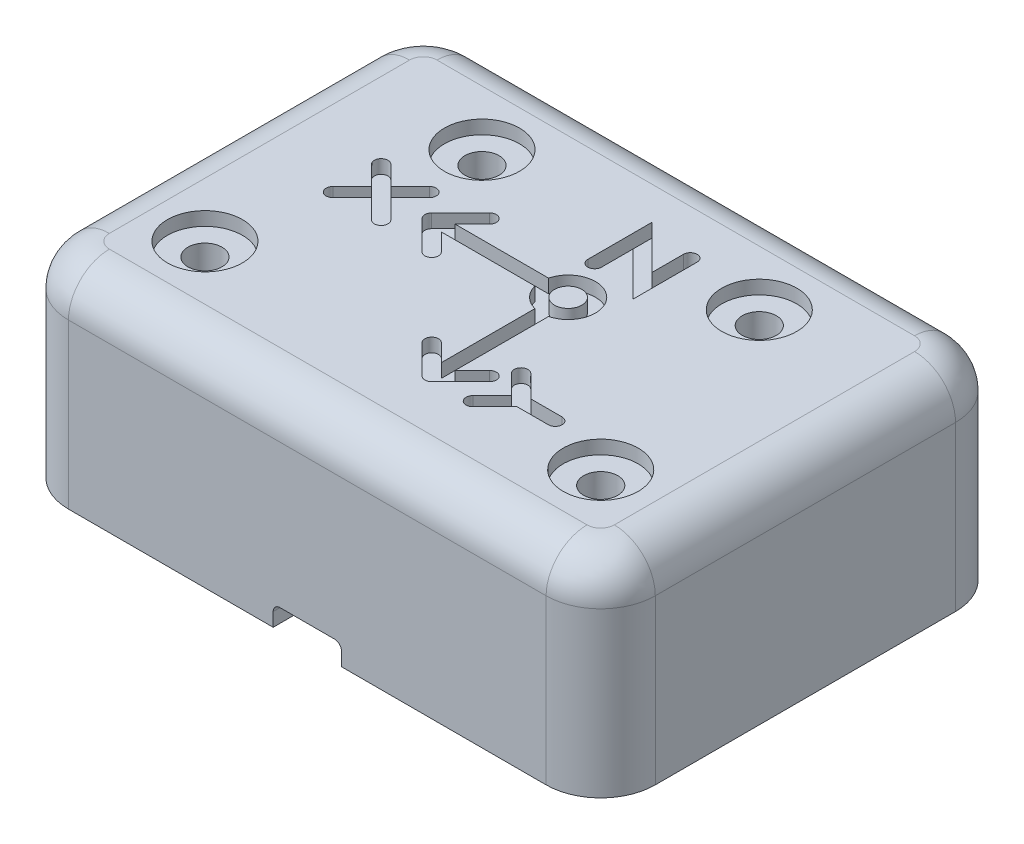
from build123d import *

# Parameters (mm, degrees)
BOSS_EXTRUDE1_DEPTH = 15
CUT_EXTRUDE1_DEPTH  = 12
FILLET1_R           = 3
FILLET2_R           = 1.5
SKETCH6_R           = 1
CUT_EXTRUDE5_DEPTH  = 1
CUT_EXTRUDE6_DEPTH  = 2
SKETCH9_R           = 1.25
CUT_EXTRUDE7_DEPTH  = 3
SKETCH10_R          = 2.75
CUT_EXTRUDE8_DEPTH  = 1


with BuildPart() as part:
    # Sketch1 → Boss-Extrude1 (new body)
    with BuildSketch(Plane(origin=(0, 0, 0), x_dir=(1, 0, 0), z_dir=(0, 1, 0))):
        with BuildLine():
            Line((4, 0), (39, 0))
            ThreePointArc((39, 0), (41.828427125, 1.171572875), (43, 4))
            Line((43, 4), (43, 26))
            ThreePointArc((43, 26), (41.828427125, 28.828427125), (39, 30))
            Line((39, 30), (4, 30))
            ThreePointArc((4, 30), (1.171572875, 28.828427125), (0, 26))
            Line((0, 26), (0, 4))
            ThreePointArc((0, 4), (1.171572875, 1.171572875), (4, 0))
        make_face()
    extrude(amount=BOSS_EXTRUDE1_DEPTH)

    # Sketch2 → Cut-Extrude1 (cut)
    with BuildSketch(Plane.XZ):
        with BuildLine():
            Line((4, -2), (39, -2))
            ThreePointArc((39, -2), (40.414213562, -2.585786438), (41, -4))
            Line((41, -4), (41, -26))
            ThreePointArc((41, -26), (40.414213562, -27.414213562), (39, -28))
            Line((39, -28), (4, -28))
            ThreePointArc((4, -28), (2.585786438, -27.414213562), (2, -26))
            Line((2, -26), (2, -4))
            ThreePointArc((2, -4), (2.585786438, -2.585786438), (4, -2))
        make_face()
    extrude(amount=-CUT_EXTRUDE1_DEPTH, mode=Mode.SUBTRACT)

    # Fillet1
    fillet1_edges = [part.edges().sort_by_distance(p)[0] for p in [
        (1.171572875, 15, -28.828427125),
        (0, 15, -15),
        (1.171572875, 15, -1.171572875),
        (21.5, 15, 0),
        (41.828427125, 15, -1.171572875),
        (43, 15, -15),
        (41.828427125, 15, -28.828427125),
        (21.5, 15, -30),
    ]]
    fillet(fillet1_edges, radius=FILLET1_R)

    # Fillet2
    fillet2_edges = [part.edges().sort_by_distance(p)[0] for p in [
        (40.414213562, 12, -27.414213562),
        (21.5, 12, -28),
        (2.585786438, 12, -27.414213562),
        (2, 12, -15),
        (2.585786438, 12, -2.585786438),
        (21.5, 12, -2),
        (40.414213562, 12, -2.585786438),
        (41, 12, -15),
    ]]
    fillet(fillet2_edges, radius=FILLET2_R)

    # Sketch6 → Cut-Extrude5 (cut)
    with BuildSketch(Plane(origin=(0, 15, 0), x_dir=(1, 0, 0), z_dir=(0, 1, 0))):
        with BuildLine():
            Line((24.365034556, 14.814527437), (24.365034556, 7.958125892))
            Line((24.365034556, 7.958125892), (25.632801509, 9.225892845))
            ThreePointArc((25.632801509, 9.225892845), (26.33990829, 9.225892845), (26.33990829, 8.518786064))
            Line((26.33990829, 8.518786064), (24.218587947, 6.39746572))
            ThreePointArc((24.218587947, 6.39746572), (23.865034556, 6.251019111), (23.511481165, 6.39746572))
            Line((23.511481165, 6.39746572), (21.390160822, 8.518786064))
            ThreePointArc((21.390160822, 8.518786064), (21.390160822, 9.225892845), (22.097267603, 9.225892845))
            Line((22.097267603, 9.225892845), (23.365034556, 7.958125892))
            Line((23.365034556, 7.958125892), (23.365034556, 14.814527437))
            ThreePointArc((23.365034556, 14.814527437), (22.450820994, 15.336805548), (21.928542883, 16.251019111))
            Line((21.928542883, 16.251019111), (15.072141337, 16.251019111))
            Line((15.072141337, 16.251019111), (16.33990829, 14.983252158))
            ThreePointArc((16.33990829, 14.983252158), (16.33990829, 14.276145376), (15.632801509, 14.276145376))
            Line((15.632801509, 14.276145376), (13.511481165, 16.39746572))
            ThreePointArc((13.511481165, 16.39746572), (13.365034556, 16.751019111), (13.511481165, 17.104572501))
            Line((13.511481165, 17.104572501), (15.632801509, 19.225892845))
            ThreePointArc((15.632801509, 19.225892845), (16.33990829, 19.225892845), (16.33990829, 18.518786064))
            Line((16.33990829, 18.518786064), (15.072141337, 17.251019111))
            Line((15.072141337, 17.251019111), (21.928542883, 17.251019111))
            ThreePointArc((21.928542883, 17.251019111), (25.279248118, 18.165232673), (24.365034556, 14.814527437))
        make_face()
        with Locations((23.865034556, 16.751019111)):
            Circle(SKETCH6_R, mode=Mode.SUBTRACT)
        with BuildLine():
            Line((26.35894309, 18.994625435), (26.35894309, 23.705411504))
            ThreePointArc((26.35894309, 23.705411504), (25.85894309, 24.205411504), (25.35894309, 23.705411504))
            Line((25.35894309, 23.705411504), (25.35894309, 21.408838997))
            Line((25.35894309, 21.408838997), (22.176962575, 24.590819512))
            Line((22.176962575, 24.590819512), (22.176962575, 19.883712731))
            ThreePointArc((22.176962575, 19.883712731), (22.676962575, 19.383712731), (23.176962575, 19.883712731))
            Line((23.176962575, 19.883712731), (23.176962575, 22.17660595))
            Line((23.176962575, 22.17660595), (26.35894309, 18.994625435))
        make_face()
        with BuildLine():
            Line((28.940475029, 7.935307593), (31.233368247, 7.935307593))
            ThreePointArc((31.233368247, 7.935307593), (31.733368247, 8.435307593), (31.233368247, 8.935307593))
            Line((31.233368247, 8.935307593), (28.940475029, 8.935307593))
            Line((28.940475029, 8.935307593), (27.319154685, 10.556627936))
            ThreePointArc((27.319154685, 10.556627936), (26.612047904, 10.556627936), (26.612047904, 9.849521155))
            Line((26.612047904, 9.849521155), (28.026261466, 8.435307593))
            Line((28.026261466, 8.435307593), (26.612047904, 7.02109403))
            ThreePointArc((26.612047904, 7.02109403), (26.612047904, 6.313987249), (27.319154685, 6.313987249))
            Line((27.319154685, 6.313987249), (28.940475029, 7.935307593))
        make_face()
        with BuildLine():
            Line((10.334787343, 15.870919893), (11.749000906, 14.456706331))
            ThreePointArc((11.749000906, 14.456706331), (12.456107687, 14.456706331), (12.456107687, 15.163813112))
            Line((12.456107687, 15.163813112), (11.041894124, 16.578026674))
            Line((11.041894124, 16.578026674), (12.456107687, 17.992240237))
            ThreePointArc((12.456107687, 17.992240237), (12.456107687, 18.699347018), (11.749000906, 18.699347018))
            Line((11.749000906, 18.699347018), (10.334787343, 17.285133456))
            Line((10.334787343, 17.285133456), (8.920573781, 18.699347018))
            ThreePointArc((8.920573781, 18.699347018), (8.213467, 18.699347018), (8.213467, 17.992240237))
            Line((8.213467, 17.992240237), (9.627680562, 16.578026674))
            Line((9.627680562, 16.578026674), (8.213467, 15.163813112))
            ThreePointArc((8.213467, 15.163813112), (8.213467, 14.456706331), (8.920573781, 14.456706331))
            Line((8.920573781, 14.456706331), (10.334787343, 15.870919893))
        make_face()
    extrude(amount=-CUT_EXTRUDE5_DEPTH, mode=Mode.SUBTRACT)

    # Sketch7 → Cut-Extrude6 (cut)
    with BuildSketch(Plane.XY):
        with BuildLine():
            Line((19, 0), (24, 0))
            Line((24, 0), (24, 1))
            ThreePointArc((24, 1), (23.853553391, 1.353553391), (23.5, 1.5))
            Line((23.5, 1.5), (19.5, 1.5))
            ThreePointArc((19.5, 1.5), (19.146446609, 1.353553391), (19, 1))
            Line((19, 1), (19, 0))
        make_face()
    extrude(amount=-CUT_EXTRUDE6_DEPTH, mode=Mode.SUBTRACT)

    # Sketch9 → Cut-Extrude7 (cut)
    with BuildSketch(Plane(origin=(0, 15, 0), x_dir=(1, 0, 0), z_dir=(0, 1, 0))):
        with Locations((7, 7)):
            Circle(SKETCH9_R)
        with Locations((11.34, 22.96)):
            Circle(SKETCH9_R)
        with Locations((31.66, 22.96)):
            Circle(SKETCH9_R)
        with Locations((36, 7)):
            Circle(SKETCH9_R)
    extrude(amount=-CUT_EXTRUDE7_DEPTH, mode=Mode.SUBTRACT)

    # Sketch10 → Cut-Extrude8 (cut)
    with BuildSketch(Plane(origin=(0, 15, 0), x_dir=(1, 0, 0), z_dir=(0, 1, 0))):
        with Locations((7, 7)):
            Circle(SKETCH10_R)
        with Locations((11.34, 22.96)):
            Circle(SKETCH10_R)
        with Locations((36, 7)):
            Circle(SKETCH10_R)
        with Locations((31.66, 22.96)):
            Circle(SKETCH10_R)
    extrude(amount=-CUT_EXTRUDE8_DEPTH, mode=Mode.SUBTRACT)


solid = part.part
